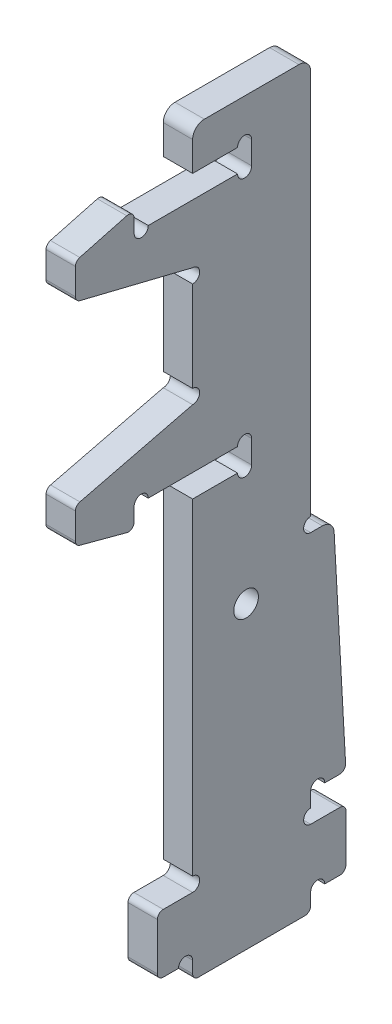
from build123d import *

# Parameters (mm, degrees)
EXTRUDE_1_DEPTH     = 1.25
EXTRUDE_2_DEPTH     = 2.5
SKETCH_3_R          = 0.6
CUT_EXTRUDE_1_DEPTH = 3.5
FILLET_1_R          = 0.5
SKETCH_5_W          = 5.025
SKETCH_5_H          = 1.95
CUT_EXTRUDE_2_DEPTH = 3.5
SKETCH_6_R          = 0.6
CUT_EXTRUDE_3_DEPTH = 3.5
CUT_EXTRUDE_4_DEPTH = 3.5
SKETCH_8_R          = 0.6
CUT_EXTRUDE_5_DEPTH = 3.5
FILLET_2_R          = 1
EXTRUDE_3_DEPTH     = 2.5
SKETCH_10_R         = 0.6
CUT_EXTRUDE_6_DEPTH = 3.5
FILLET_3_R          = 0.5
SKETCH_11_R         = 1.05
CUT_EXTRUDE_7_DEPTH = 3.5


with BuildPart() as part:
    # 草图2 → 凸台-拉伸1 (new body, symmetric)
    with BuildSketch(Plane(origin=(0, 0, 0), x_dir=(0, 0, -1), z_dir=(1, 0, 0))):
        Polygon((-5.025, 65), (-5.025, 8.5), (-8.025, 8.5), (-8.025, 3.5), (-5.025, 3.5), (-5.025, 2), (5.025, 2), (5.025, 3.5), (8.025, 3.5), (8.025, 8.5), (5.025, 8.5), (5.025, 65), align=None)
    extrude(amount=EXTRUDE_1_DEPTH, both=True)

    # 草图4 → 凸台-拉伸2 (add)
    with BuildSketch(Plane.ZY.offset(1.25)):
        Polygon((-5.025, 65), (-8.025, 10.95), (-5.025, 10.95), align=None)
    extrude(amount=-EXTRUDE_2_DEPTH)

    # 草图3 → 切除-拉伸1 (cut, through all)
    with BuildSketch(Plane(origin=(1.25, 0, 0), x_dir=(0, 0, -1), z_dir=(1, 0, 0))):
        with Locations((-5.025, 9.1)):
            Circle(SKETCH_3_R)
        with Locations((-5.625, 3.5)):
            Circle(SKETCH_3_R)
        with Locations((5.025, 9.1)):
            Circle(SKETCH_3_R)
        with Locations((5.625, 3.5)):
            Circle(SKETCH_3_R)
        with Locations((5.625, 10.95)):
            Circle(SKETCH_3_R)
    extrude(amount=-CUT_EXTRUDE_1_DEPTH, mode=Mode.SUBTRACT)

    # 圆角1
    fillet_1_edges = [part.edges().sort_by_distance(p)[0] for p in [
        (0, 8.5, -8.025),
        (0, 3.5, -8.025),
        (0, 2, -5.025),
        (0, 2, 5.025),
        (0, 3.5, 8.025),
        (0, 8.5, 8.025),
        (0, 10.95, -8.025),
    ]]
    fillet(fillet_1_edges, radius=FILLET_1_R)

    # 草图5 → 切除-拉伸2 (cut, through all)
    with BuildSketch(Plane(origin=(1.25, 0, 0), x_dir=(0, 0, -1), z_dir=(1, 0, 0))):
        with Locations((-2.5125, 38.475)):
            Rectangle(SKETCH_5_W, SKETCH_5_H)
        with Locations((-2.5125, 60.525)):
            Rectangle(SKETCH_5_W, SKETCH_5_H)
    extrude(amount=-CUT_EXTRUDE_2_DEPTH, mode=Mode.SUBTRACT)

    # 草图6 → 切除-拉伸3 (cut, through all)
    with BuildSketch(Plane(origin=(1.25, 0, 0), x_dir=(0, 0, -1), z_dir=(1, 0, 0))):
        with Locations((-0.6, 61.5)):
            Circle(SKETCH_6_R)
        with Locations((-0.6, 59.55)):
            Circle(SKETCH_6_R)
        with Locations((-0.6, 39.45)):
            Circle(SKETCH_6_R)
        with Locations((-0.6, 37.5)):
            Circle(SKETCH_6_R)
    extrude(amount=-CUT_EXTRUDE_3_DEPTH, mode=Mode.SUBTRACT)

    # 草图7 → 切除-拉伸4 (cut, through all)
    with BuildSketch(Plane.ZY.offset(1.25)):
        Polygon((-5.025, 65), (-5.025, 30), (-6.967645698, 30), align=None)
    extrude(amount=-CUT_EXTRUDE_4_DEPTH, mode=Mode.SUBTRACT)

    # 草图8 → 切除-拉伸5 (cut, through all)
    with BuildSketch(Plane.ZY.offset(1.25)):
        with Locations((-5.025, 30.6)):
            Circle(SKETCH_8_R)
    extrude(amount=-CUT_EXTRUDE_5_DEPTH, mode=Mode.SUBTRACT)

    # 圆角2
    fillet_2_edges = [part.edges().sort_by_distance(p)[0] for p in [
        (0, 65, -5.025),
        (0, 30, -6.967645698),
        (0, 65, 5.025),
    ]]
    fillet(fillet_2_edges, radius=FILLET_2_R)

    # 草图9 → 凸台-拉伸3 (add)
    with BuildSketch(Plane.ZY.offset(1.25)):
        Polygon((5.025, 59.55), (10, 59.55), (10, 61.35), (15, 60.010254038), (15, 57.010254038), (5.025, 54.55), align=None)
        Polygon((15, 41.989745962), (5.025, 44.45), (5.025, 39.45), (10, 39.45), (10, 37.65), (15, 38.989745962), align=None)
    extrude(amount=-EXTRUDE_3_DEPTH)

    # 草图10 → 切除-拉伸6 (cut, through all)
    with BuildSketch(Plane.ZY.offset(1.25)):
        with Locations((5.025, 53.95)):
            Circle(SKETCH_10_R)
        with Locations((5.025, 45.05)):
            Circle(SKETCH_10_R)
        with Locations((9.4, 59.55)):
            Circle(SKETCH_10_R)
        with Locations((9.4, 39.45)):
            Circle(SKETCH_10_R)
    extrude(amount=-CUT_EXTRUDE_6_DEPTH, mode=Mode.SUBTRACT)

    # 圆角3
    fillet_3_edges = [part.edges().sort_by_distance(p)[0] for p in [
        (0, 61.35, 10),
        (0, 60.010254038, 15),
        (0, 57.010254038, 15),
        (0, 41.989745962, 15),
        (0, 38.989745962, 15),
        (0, 37.65, 10),
    ]]
    fillet(fillet_3_edges, radius=FILLET_3_R)

    # 草图11 → 切除-拉伸7 (cut, through all)
    with BuildSketch(Plane(origin=(1.25, 0, 0), x_dir=(0, 0, -1), z_dir=(1, 0, 0))):
        with Locations((-0.475, 27.5)):
            Circle(SKETCH_11_R)
    extrude(amount=-CUT_EXTRUDE_7_DEPTH, mode=Mode.SUBTRACT)


solid = part.part
